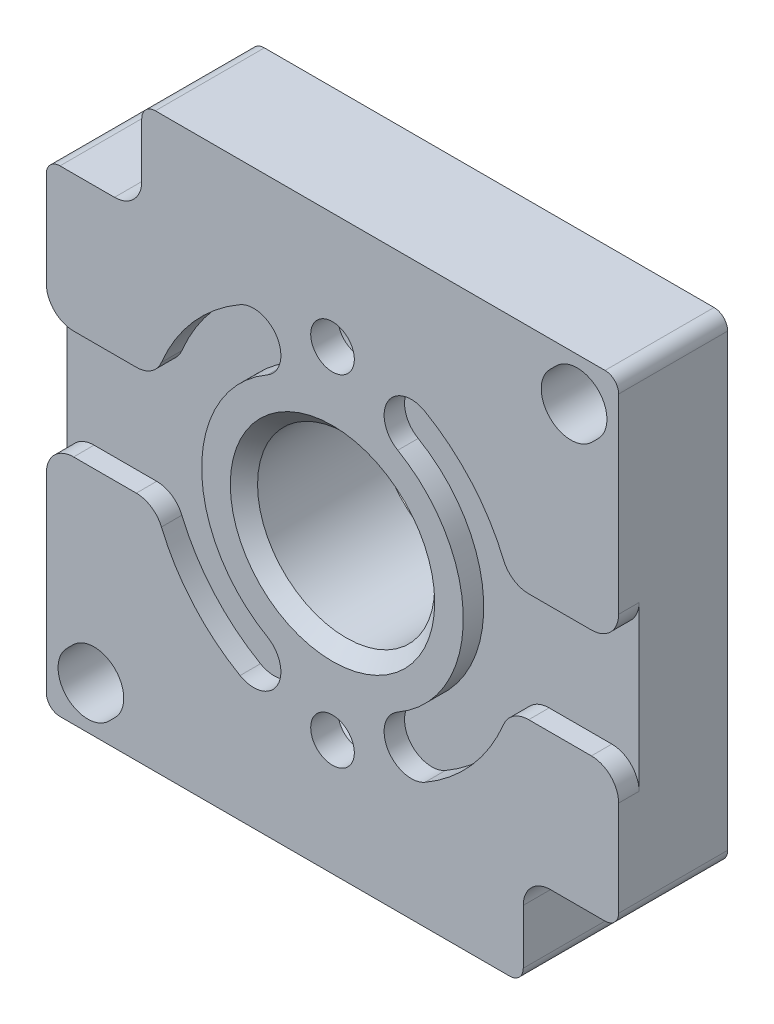
from build123d import *

# Parameters (mm, degrees)
SKETCH1_W                      = 42
SKETCH1_H                      = 42
BOSS_EXTRUDE1_DEPTH            = 8
BOSS_EXTRUDE2_DEPTH            = 1.8
CUT_EXTRUDE1_DEPTH             = 6
CUT_EXTRUDE2_DEPTH             = 6
CUT_EXTRUDE3_DEPTH             = 6
CUT_EXTRUDE4_DEPTH             = 6
CUT_EXTRUDE5_DEPTH             = 1.5
CUT_EXTRUDE6_DEPTH             = 1.5
SKETCH9_W                      = 7
SKETCH9_H                      = 7
CUT_EXTRUDE7_DEPTH             = 10.8
SKETCH10_W                     = 7
SKETCH10_H                     = 7
CUT_EXTRUDE8_DEPTH             = 10.8
CUT_EXTRUDE9_DEPTH             = 9
CUT_EXTRUDE10_DEPTH            = 10.8
CUT_EXTRUDE11_DEPTH            = 7.8
CUT_EXTRUDE12_DEPTH            = 7.8
CUT_EXTRUDE13_DEPTH            = 7.8
CUT_EXTRUDE14_DEPTH            = 7.8
CUT_EXTRUDE15_DEPTH            = 7.8
CUT_EXTRUDE16_DEPTH            = 7.8
F_3_2_3_2_DIAMETER_HOLE1_D     = 3.2
F_3_2_3_2_DIAMETER_HOLE1_DEPTH = 2
F_13_0_13_DIAMETER_HOLE1_D     = 13
F_13_0_13_DIAMETER_HOLE1_DEPTH = 9.8
CHAMFER1_SIZE                  = 1
CHAMFER2_SIZE                  = 0.5
FILLET1_R                      = 1
FILLET2_R                      = 2
FILLET3_R                      = 4


with BuildPart() as part:
    # Sketch1 → Boss-Extrude1 (new body)
    with BuildSketch(Plane(origin=(0, 0, -7), x_dir=(-1, 0, 0), z_dir=(0, 0, -1))):
        Rectangle(SKETCH1_W, SKETCH1_H)
    extrude(amount=-BOSS_EXTRUDE1_DEPTH)

    # Sketch2 → Boss-Extrude2 (add)
    with BuildSketch(Plane(origin=(0, 0, -7), x_dir=(-1, 0, 0), z_dir=(0, 0, -1))):
        with BuildLine():
            ThreePointArc((3.198182046, -13.078041176), (0, -9.25), (-3.198182046, -13.078041176))
            ThreePointArc((-3.198182046, -13.078041176), (-3.52135457, -14.006388516), (-4.483118496, -14.209561871))
            ThreePointArc((-4.483118496, -14.209561871), (-14.9, 0), (-4.483118496, 14.209561871))
            ThreePointArc((-4.483118496, 14.209561871), (-3.52135457, 14.006388516), (-3.198182046, 13.078041176))
            ThreePointArc((-3.198182046, 13.078041176), (0, 9.25), (3.198182046, 13.078041176))
            ThreePointArc((3.198182046, 13.078041176), (3.52135457, 14.006388516), (4.483118496, 14.209561871))
            ThreePointArc((4.483118496, 14.209561871), (14.9, 0), (4.483118496, -14.209561871))
            ThreePointArc((4.483118496, -14.209561871), (3.52135457, -14.006388516), (3.198182046, -13.078041176))
        make_face()
    extrude(amount=BOSS_EXTRUDE2_DEPTH)

    # Sketch3 → Cut-Extrude1 (cut)
    with BuildSketch(Plane(origin=(0, 0, -7), x_dir=(-1, 0, 0), z_dir=(0, 0, -1))):
        with BuildLine():
            Line((13.566710468, 6.160711573), (19, 8.411253785))
            Line((19, 8.411253785), (19, 12))
            Line((19, 12), (12, 12))
            Line((12, 12), (12, 19))
            Line((12, 19), (-13.59841058, 19))
            ThreePointArc((-13.59841058, 19), (-14.544293655, 14.544293655), (-19, 13.59841058))
            Line((-19, 13.59841058), (-19, 8.411253785))
            Line((-19, 8.411253785), (-13.566710468, 6.160711573))
            ThreePointArc((-13.566710468, 6.160711573), (-9.881552468, 11.151902116), (-4.483118496, 14.209561871))
            ThreePointArc((-4.483118496, 14.209561871), (-3.52135457, 14.006388516), (-3.198182046, 13.078041176))
            ThreePointArc((-3.198182046, 13.078041176), (0, 9.25), (3.198182046, 13.078041176))
            ThreePointArc((3.198182046, 13.078041176), (3.52135457, 14.006388516), (4.483118496, 14.209561871))
            ThreePointArc((4.483118496, 14.209561871), (9.881552468, 11.151902116), (13.566710468, 6.160711573))
        make_face()
    extrude(amount=-CUT_EXTRUDE1_DEPTH, mode=Mode.SUBTRACT)

    # Sketch4 → Cut-Extrude2 (cut)
    with BuildSketch(Plane(origin=(0, 0, -7), x_dir=(-1, 0, 0), z_dir=(0, 0, -1))):
        with BuildLine():
            Line((-13.9493939, 5.23683204), (-19, 7.328861585))
            Line((-19, 7.328861585), (-19, -7.328861585))
            Line((-19, -7.328861585), (-13.9493939, -5.23683204))
            ThreePointArc((-13.9493939, -5.23683204), (-14.9, 0), (-13.9493939, 5.23683204))
        make_face()
    extrude(amount=-CUT_EXTRUDE2_DEPTH, mode=Mode.SUBTRACT)

    # Sketch5 → Cut-Extrude3 (cut)
    with BuildSketch(Plane(origin=(0, 0, -7), x_dir=(-1, 0, 0), z_dir=(0, 0, -1))):
        with BuildLine():
            Line((-13.566710468, -6.160711573), (-19, -8.411253785))
            Line((-19, -8.411253785), (-19, -12))
            Line((-19, -12), (-12, -12))
            Line((-12, -12), (-12, -19))
            Line((-12, -19), (13.59841058, -19))
            ThreePointArc((13.59841058, -19), (14.544293655, -14.544293655), (19, -13.59841058))
            Line((19, -13.59841058), (19, -8.411253785))
            Line((19, -8.411253785), (13.566710468, -6.160711573))
            ThreePointArc((13.566710468, -6.160711573), (9.881552468, -11.151902116), (4.483118496, -14.209561871))
            ThreePointArc((4.483118496, -14.209561871), (3.52135457, -14.006388516), (3.198182046, -13.078041176))
            ThreePointArc((3.198182046, -13.078041176), (0, -9.25), (-3.198182046, -13.078041176))
            ThreePointArc((-3.198182046, -13.078041176), (-3.52135457, -14.006388516), (-4.483118496, -14.209561871))
            ThreePointArc((-4.483118496, -14.209561871), (-9.881552468, -11.151902116), (-13.566710468, -6.160711573))
        make_face()
    extrude(amount=-CUT_EXTRUDE3_DEPTH, mode=Mode.SUBTRACT)

    # Sketch6 → Cut-Extrude4 (cut)
    with BuildSketch(Plane(origin=(0, 0, -7), x_dir=(-1, 0, 0), z_dir=(0, 0, -1))):
        with BuildLine():
            Line((13.9493939, -5.23683204), (19, -7.328861585))
            Line((19, -7.328861585), (19, 7.328861585))
            Line((19, 7.328861585), (13.9493939, 5.23683204))
            ThreePointArc((13.9493939, 5.23683204), (14.9, 0), (13.9493939, -5.23683204))
        make_face()
    extrude(amount=-CUT_EXTRUDE4_DEPTH, mode=Mode.SUBTRACT)

    # Sketch7 → Cut-Extrude5 (cut)
    with BuildSketch(Plane.XY.offset(1)):
        with BuildLine():
            Line((21, 4), (12.998461447, 4))
            ThreePointArc((12.998461447, 4), (10.630422419, 8.482577391), (6.785233496, 11.786458603))
            ThreePointArc((6.785233496, 11.786458603), (4.054102305, 11.050984323), (4.789576586, 8.319853131))
            ThreePointArc((4.789576586, 8.319853131), (9.6, 0), (4.789576586, -8.319853131))
            ThreePointArc((4.789576586, -8.319853131), (4.054102305, -11.050984323), (6.785233496, -11.786458603))
            ThreePointArc((6.785233496, -11.786458603), (10.630422419, -8.482577391), (12.998461447, -4))
            Line((12.998461447, -4), (21, -4))
            Line((21, -4), (21, 4))
        make_face()
    extrude(amount=-CUT_EXTRUDE5_DEPTH, mode=Mode.SUBTRACT)

    # Sketch8 → Cut-Extrude6 (cut)
    with BuildSketch(Plane.XY.offset(1)):
        with BuildLine():
            Line((-21, -4), (-12.998461447, -4))
            ThreePointArc((-12.998461447, -4), (-10.630422419, -8.482577391), (-6.785233496, -11.786458603))
            ThreePointArc((-6.785233496, -11.786458603), (-4.054102305, -11.050984323), (-4.789576586, -8.319853131))
            ThreePointArc((-4.789576586, -8.319853131), (-9.6, 0), (-4.789576586, 8.319853131))
            ThreePointArc((-4.789576586, 8.319853131), (-4.054102305, 11.050984323), (-6.785233496, 11.786458603))
            ThreePointArc((-6.785233496, 11.786458603), (-10.630422419, 8.482577391), (-12.998461447, 4))
            Line((-12.998461447, 4), (-21, 4))
            Line((-21, 4), (-21, -4))
        make_face()
    extrude(amount=-CUT_EXTRUDE6_DEPTH, mode=Mode.SUBTRACT)

    # Sketch9 → Cut-Extrude7 (cut, through all)
    with BuildSketch(Plane.XY.offset(1)):
        with Locations((-17.5, 17.5)):
            Rectangle(SKETCH9_W, SKETCH9_H)
    extrude(amount=-CUT_EXTRUDE7_DEPTH, mode=Mode.SUBTRACT)

    # Sketch10 → Cut-Extrude8 (cut, through all)
    with BuildSketch(Plane.XY.offset(1)):
        with Locations((17.5, -17.5)):
            Rectangle(SKETCH10_W, SKETCH10_H)
    extrude(amount=-CUT_EXTRUDE8_DEPTH, mode=Mode.SUBTRACT)

    # Sketch11 → Cut-Extrude9 (cut, through all)
    with BuildSketch(Plane(origin=(0, 0, -7), x_dir=(-1, 0, 0), z_dir=(0, 0, -1))):
        with BuildLine():
            Line((-15.958507217, 19.041492783), (-16.419019459, 19.502005025))
            ThreePointArc((-16.419019459, 19.502005025), (-19.502005025, 19.502005025), (-19.502005025, 16.419019459))
            Line((-19.502005025, 16.419019459), (-19.041492783, 15.958507217))
            ThreePointArc((-19.041492783, 15.958507217), (-15.958507217, 15.958507217), (-15.958507217, 19.041492783))
        make_face()
    extrude(amount=-CUT_EXTRUDE9_DEPTH, mode=Mode.SUBTRACT)

    # Sketch12 → Cut-Extrude10 (cut, through all)
    with BuildSketch(Plane.XY.offset(1)):
        with BuildLine():
            Line((-16.419019459, -19.502005025), (-15.958507217, -19.041492783))
            ThreePointArc((-15.958507217, -19.041492783), (-15.958507217, -15.958507217), (-19.041492783, -15.958507217))
            Line((-19.041492783, -15.958507217), (-19.502005025, -16.419019459))
            ThreePointArc((-19.502005025, -16.419019459), (-19.502005025, -19.502005025), (-16.419019459, -19.502005025))
        make_face()
    extrude(amount=-CUT_EXTRUDE10_DEPTH, mode=Mode.SUBTRACT)

    # Sketch13 → Cut-Extrude11 (cut)
    with BuildSketch(Plane(origin=(0, 0, -8.8), x_dir=(-1, 0, 0), z_dir=(0, 0, -1))):
        with BuildLine():
            Line((12.180022738, -5.586326708), (7.648036073, -3.709116367))
            ThreePointArc((7.648036073, -3.709116367), (6.017854446, -6.002951597), (3.728068311, -7.638815789))
            ThreePointArc((3.728068311, -7.638815789), (3.182506601, -8.360206271), (3.442027264, -9.226630435))
            ThreePointArc((3.442027264, -9.226630435), (4.416428384, -10.751383309), (4.749905893, -12.5299))
            ThreePointArc((4.749905893, -12.5299), (9.149258078, -9.790356307), (12.180022738, -5.586326708))
        make_face()
    extrude(amount=-CUT_EXTRUDE11_DEPTH, mode=Mode.SUBTRACT)

    # Sketch14 → Cut-Extrude12 (cut)
    with BuildSketch(Plane(origin=(0, 0, -8.8), x_dir=(-1, 0, 0), z_dir=(0, 0, -1))):
        with BuildLine():
            Line((-12.180022738, 5.586326708), (-7.648036073, 3.709116367))
            ThreePointArc((-7.648036073, 3.709116367), (-6.017854446, 6.002951597), (-3.728068311, 7.638815789))
            ThreePointArc((-3.728068311, 7.638815789), (-3.182506601, 8.360206271), (-3.442027264, 9.226630435))
            ThreePointArc((-3.442027264, 9.226630435), (-4.416428384, 10.751383309), (-4.749905893, 12.5299))
            ThreePointArc((-4.749905893, 12.5299), (-9.149258078, 9.790356307), (-12.180022738, 5.586326708))
        make_face()
    extrude(amount=-CUT_EXTRUDE12_DEPTH, mode=Mode.SUBTRACT)

    # Sketch15 → Cut-Extrude13 (cut)
    with BuildSketch(Plane(origin=(0, 0, -8.8), x_dir=(-1, 0, 0), z_dir=(0, 0, -1))):
        with BuildLine():
            Line((7.648036073, 3.709116367), (12.180022738, 5.586326708))
            ThreePointArc((12.180022738, 5.586326708), (9.149258078, 9.790356307), (4.749905893, 12.5299))
            ThreePointArc((4.749905893, 12.5299), (4.416428384, 10.751383309), (3.442027264, 9.226630435))
            ThreePointArc((3.442027264, 9.226630435), (3.182506601, 8.360206271), (3.728068311, 7.638815789))
            ThreePointArc((3.728068311, 7.638815789), (6.017854446, 6.002951597), (7.648036073, 3.709116367))
        make_face()
    extrude(amount=-CUT_EXTRUDE13_DEPTH, mode=Mode.SUBTRACT)

    # Sketch16 → Cut-Extrude14 (cut)
    with BuildSketch(Plane(origin=(0, 0, -8.8), x_dir=(-1, 0, 0), z_dir=(0, 0, -1))):
        with BuildLine():
            Line((-7.648036073, -3.709116367), (-12.180022738, -5.586326708))
            ThreePointArc((-12.180022738, -5.586326708), (-9.149258078, -9.790356307), (-4.749905893, -12.5299))
            ThreePointArc((-4.749905893, -12.5299), (-4.416428384, -10.751383309), (-3.442027264, -9.226630435))
            ThreePointArc((-3.442027264, -9.226630435), (-3.182506601, -8.360206271), (-3.728068311, -7.638815789))
            ThreePointArc((-3.728068311, -7.638815789), (-6.017854446, -6.002951597), (-7.648036073, -3.709116367))
        make_face()
    extrude(amount=-CUT_EXTRUDE14_DEPTH, mode=Mode.SUBTRACT)

    # Sketch17 → Cut-Extrude15 (cut)
    with BuildSketch(Plane(origin=(0, 0, -8.8), x_dir=(-1, 0, 0), z_dir=(0, 0, -1))):
        with BuildLine():
            Line((-12.562706171, -4.662447176), (-8.030719505, -2.785236835))
            ThreePointArc((-8.030719505, -2.785236835), (-8.5, 0), (-8.030719505, 2.785236835))
            Line((-8.030719505, 2.785236835), (-12.562706171, 4.662447176))
            ThreePointArc((-12.562706171, 4.662447176), (-13.4, 0), (-12.562706171, -4.662447176))
        make_face()
    extrude(amount=-CUT_EXTRUDE15_DEPTH, mode=Mode.SUBTRACT)

    # Sketch18 → Cut-Extrude16 (cut)
    with BuildSketch(Plane(origin=(0, 0, -8.8), x_dir=(-1, 0, 0), z_dir=(0, 0, -1))):
        with BuildLine():
            Line((8.030719505, -2.785236835), (12.562706171, -4.662447176))
            ThreePointArc((12.562706171, -4.662447176), (13.4, 0), (12.562706171, 4.662447176))
            Line((12.562706171, 4.662447176), (8.030719505, 2.785236835))
            ThreePointArc((8.030719505, 2.785236835), (8.5, 0), (8.030719505, -2.785236835))
        make_face()
    extrude(amount=-CUT_EXTRUDE16_DEPTH, mode=Mode.SUBTRACT)

    # Ø3.2 (3.2) Diameter Hole1
    with Locations(Plane(origin=(0, 0, -1), x_dir=(-1, 0, 0), z_dir=(0, 0, -1))):
        with Locations((0, -12.5), (0, 12.5)):
            Hole(F_3_2_3_2_DIAMETER_HOLE1_D / 2, depth=F_3_2_3_2_DIAMETER_HOLE1_DEPTH)

    # Ø13.0 (13) Diameter Hole1
    with Locations(Plane.XY.offset(1)):
        with Locations((0, 0)):
            Hole(F_13_0_13_DIAMETER_HOLE1_D / 2, depth=F_13_0_13_DIAMETER_HOLE1_DEPTH)

    # Chamfer1
    chamfer1_edges = [part.edges().sort_by_distance(p)[0] for p in [
        (6.5, 0, 1),
    ]]
    chamfer(chamfer1_edges, length=CHAMFER1_SIZE)

    # Chamfer2
    chamfer2_edges = [part.edges().sort_by_distance(p)[0] for p in [
        (-3.52135457, -14.006388516, -8.8),
        (-14.9, 0, -8.8),
        (-3.52135457, 14.006388516, -8.8),
        (0, 9.25, -8.8),
        (3.52135457, 14.006388516, -8.8),
        (14.9, 0, -8.8),
        (3.52135457, -14.006388516, -8.8),
        (0, -9.25, -8.8),
    ]]
    chamfer(chamfer2_edges, length=CHAMFER2_SIZE)

    # Fillet1
    fillet1_edges = [part.edges().sort_by_distance(p)[0] for p in [
        (-21, 14, -3),
        (-14, 21, -3),
        (21, -14, -3),
        (14, -21, -3),
        (-7.648036073, -3.709116367, -4.9),
        (-12.180022738, -5.586326708, -4.9),
        (-4.749905893, -12.5299, -4.9),
        (7.648036073, 3.709116367, -4.9),
        (12.180022738, 5.586326708, -4.9),
        (4.749905893, 12.5299, -4.9),
        (-4.749905893, 12.5299, -4.9),
        (-12.180022738, 5.586326708, -4.9),
        (-7.648036073, 3.709116367, -4.9),
        (4.749905893, -12.5299, -4.9),
        (12.180022738, -5.586326708, -4.9),
        (7.648036073, -3.709116367, -4.9),
        (12.562706171, -4.662447176, -4.9),
        (12.562706171, 4.662447176, -4.9),
        (8.030719505, 2.785236835, -4.9),
        (8.030719505, -2.785236835, -4.9),
        (-8.030719505, -2.785236835, -4.9),
        (-8.030719505, 2.785236835, -4.9),
        (-12.562706171, 4.662447176, -4.9),
        (-12.562706171, -4.662447176, -4.9),
        (21, 21, -3),
        (-21, -21, -3),
    ]]
    fillet(fillet1_edges, radius=FILLET1_R)

    # Fillet2
    fillet2_edges = [part.edges().sort_by_distance(p)[0] for p in [
        (21, 4, 0.25),
        (21, -4, 0.25),
        (12.998461447, -4, 0.25),
        (12.998461447, 4, 0.25),
        (-21, -4, 0.25),
        (-21, 4, 0.25),
        (-12.998461447, 4, 0.25),
        (-12.998461447, -4, 0.25),
        (-14, 14, -3),
        (14, -14, -3),
    ]]
    fillet(fillet2_edges, radius=FILLET2_R)

    # Fillet3
    fillet3_edges = [part.edges().sort_by_distance(p)[0] for p in [
        (-12, 12, -4),
        (12, -12, -4),
    ]]
    fillet(fillet3_edges, radius=FILLET3_R)


solid = part.part
